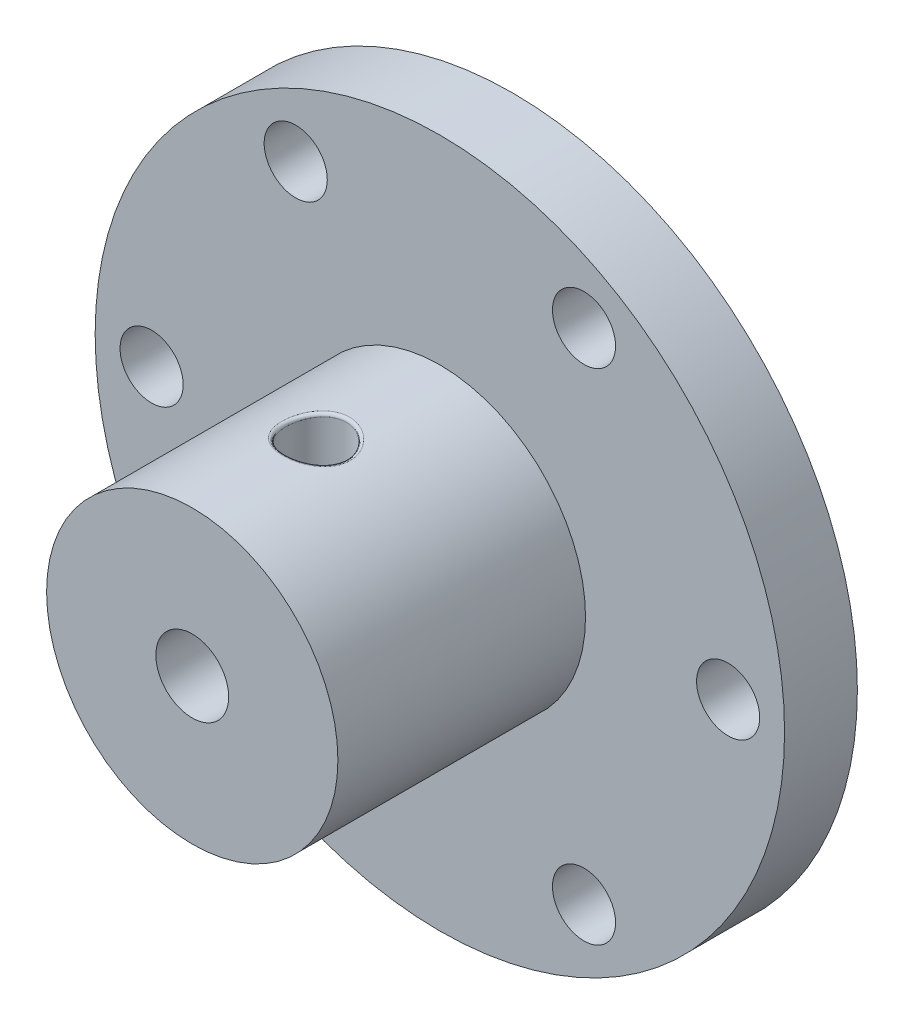
from build123d import *

# Parameters (mm, degrees)
SKETCH1_R           = 28.4
BOSS_EXTRUDE1_DEPTH = 6
SKETCH2_R           = 2.6
CUT_EXTRUDE1_DEPTH  = 7
SKETCH3_R           = 12
BOSS_EXTRUDE2_DEPTH = 20.4
SKETCH4_R           = 3
CUT_EXTRUDE2_DEPTH  = 27.4
SKETCH5_R           = 2.5
CUT_EXTRUDE3_DEPTH  = 20.4
FILLET1_R           = 0.25


with BuildPart() as part:
    # Sketch1 → Boss-Extrude1 (new body)
    with BuildSketch(Plane.XY):
        Circle(SKETCH1_R)
    extrude(amount=BOSS_EXTRUDE1_DEPTH)

    # Sketch2 → Cut-Extrude1 (cut, through all)
    with BuildSketch(Plane.XY.offset(6)):
        with Locations((23.75, 0)):
            Circle(SKETCH2_R)
        with Locations((11.875, -20.56810334)):
            Circle(SKETCH2_R)
        with Locations((-11.875, -20.56810334)):
            Circle(SKETCH2_R)
        with Locations((-23.75, 0)):
            Circle(SKETCH2_R)
        with Locations((-11.875, 20.56810334)):
            Circle(SKETCH2_R)
        with Locations((11.875, 20.56810334)):
            Circle(SKETCH2_R)
    extrude(amount=-CUT_EXTRUDE1_DEPTH, mode=Mode.SUBTRACT)

    # Sketch3 → Boss-Extrude2 (add)
    with BuildSketch(Plane.XY.offset(6)):
        Circle(SKETCH3_R)
    extrude(amount=BOSS_EXTRUDE2_DEPTH)

    # Sketch4 → Cut-Extrude2 (cut, through all)
    with BuildSketch(Plane.XY.offset(26.4)):
        Circle(SKETCH4_R)
    extrude(amount=-CUT_EXTRUDE2_DEPTH, mode=Mode.SUBTRACT)

    # Sketch5 → Cut-Extrude3 (cut)
    with BuildSketch(Plane(origin=(0, 0, 0), x_dir=(1, 0, 0), z_dir=(0, 1, 0))):
        with Locations((0, -16.2)):
            Circle(SKETCH5_R)
    extrude(amount=CUT_EXTRUDE3_DEPTH, mode=Mode.SUBTRACT)

    # Fillet1
    fillet1_edges = [part.edges().sort_by_distance(p)[0] for p in [
        (-2.500000051, 11.736694588, 16.200000004),
    ]]
    fillet(fillet1_edges, radius=FILLET1_R)


solid = part.part
